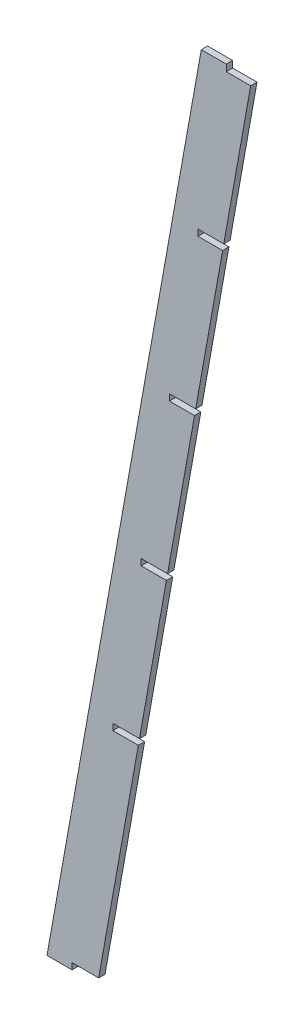
from build123d import *

# Parameters (mm, degrees)
SKETCH1_W          = 25.4
SKETCH1_H          = 3.175
SKETCH2_W          = 25.4
SKETCH2_H          = 3.175
CUT_EXTRUDE1_DEPTH = 5.08


with BuildPart() as part:
    # Sketch1 → Loft1 section 0
    with BuildSketch(Plane(origin=(0, 0, 0), x_dir=(1, 0, 0), z_dir=(0, 1, 0))):
        with Locations((12.7, 1.5875)):
            Rectangle(SKETCH1_W, SKETCH1_H)
    # Sketch2 → Loft1 section 1
    with BuildSketch(Plane(origin=(0, 432.562, 0), x_dir=(1, 0, 0), z_dir=(0, 1, 0))):
        with Locations((90.17, 1.5875)):
            Rectangle(SKETCH2_W, SKETCH2_H)
    loft()

    # Sketch3 → Cut-Extrude1 (cut)
    with BuildSketch(Plane.XY):
        Polygon((90.028717652, 432.562), (90.028717652, 429.26), (102.278625954, 429.26), (102.87, 432.562), align=None)
        Polygon((12.572909357, 3.175), (12.572909357, 0), (25.4, 0), (25.96862889, 3.175), align=None)
        Polygon((33.071424259, 117.475), (33.071424259, 114.3), (45.870640047, 114.3), (46.439268937, 117.475), align=None)
        Polygon((75.759721917, 353.738084411), (75.759721917, 350.595188566), (88.190095427, 350.595188566), (88.752974601, 353.738084411), align=None)
        Polygon((61.470871422, 274.955), (61.470871422, 271.78), (74.074633001, 271.78), (74.643261891, 274.955), align=None)
        Polygon((47.260398049, 193.04), (47.260398049, 196.215), (60.541265414, 196.215), (59.972636524, 193.04), align=None)
    extrude(amount=-CUT_EXTRUDE1_DEPTH, mode=Mode.SUBTRACT)


solid = part.part
